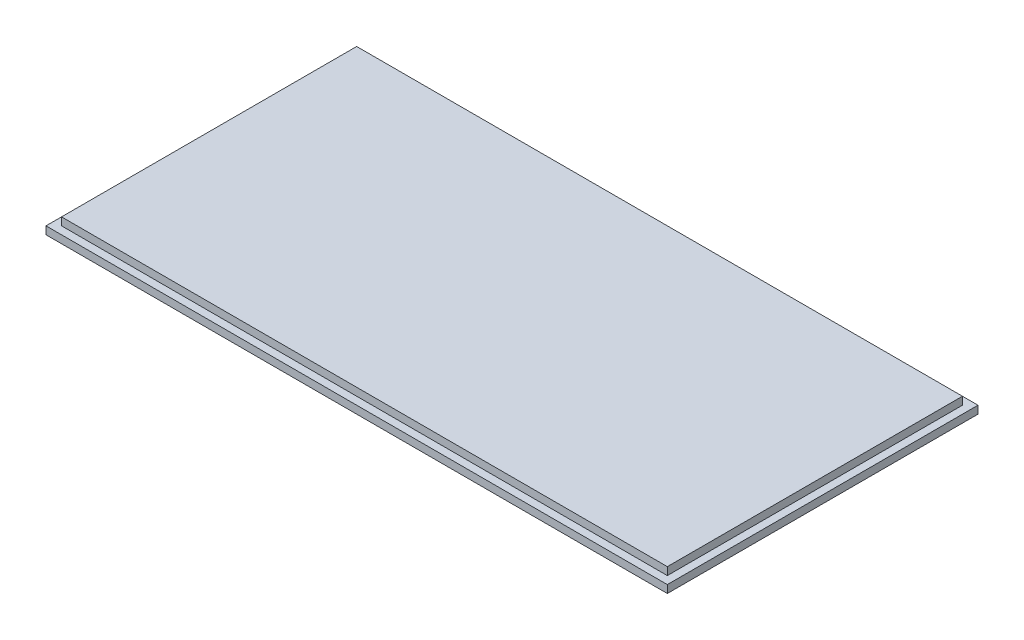
from build123d import *

# Parameters (mm, degrees)
SKETCH1_W           = 120
SKETCH1_H           = 60
BOSS_EXTRUDE1_DEPTH = 3
SKETCH2_OUTSIDE_W   = 148.84
SKETCH2_OUTSIDE_H   = 88.84
SKETCH2_OUTSIDE_W_2 = 117
SKETCH2_OUTSIDE_H_2 = 57
CUT_EXTRUDE1_DEPTH  = 1.5


with BuildPart() as part:
    # Sketch1 → Boss-Extrude1 (new body)
    with BuildSketch(Plane(origin=(0, 0, 0), x_dir=(1, 0, 0), z_dir=(0, 1, 0))):
        Rectangle(SKETCH1_W, SKETCH1_H)
    extrude(amount=BOSS_EXTRUDE1_DEPTH)

    # Sketch2 outside → Cut-Extrude1 (cut)
    with BuildSketch(Plane(origin=(0, 3, 0), x_dir=(1, 0, 0), z_dir=(0, 1, 0))):
        Rectangle(SKETCH2_OUTSIDE_W, SKETCH2_OUTSIDE_H)
        Rectangle(SKETCH2_OUTSIDE_W_2, SKETCH2_OUTSIDE_H_2, mode=Mode.SUBTRACT)
    extrude(amount=-CUT_EXTRUDE1_DEPTH, mode=Mode.SUBTRACT)


solid = part.part
